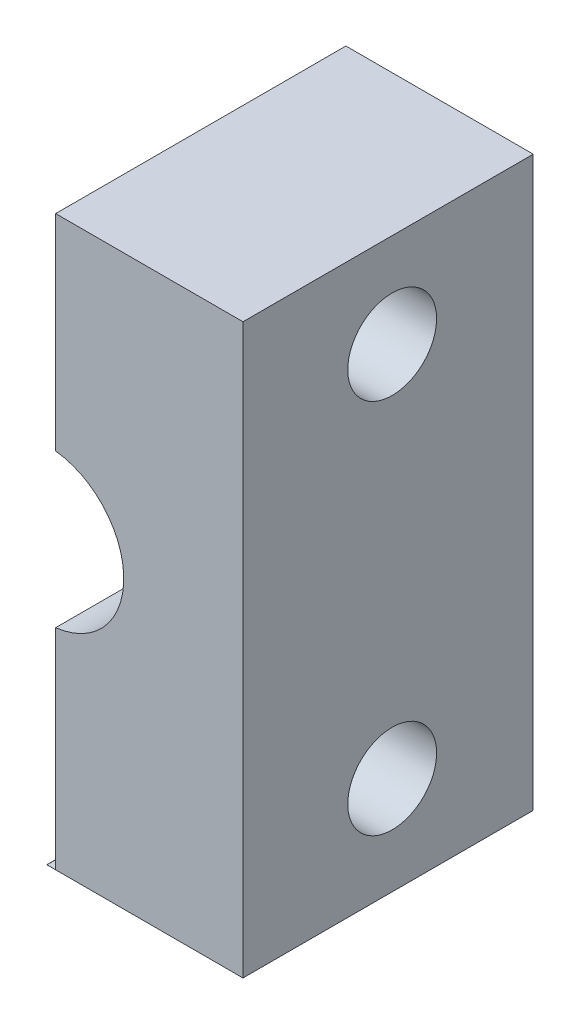
from build123d import *

# Parameters (mm, degrees)
EXTRUDE1_DEPTH = 9.8
SKETCH7_R      = 1.5
EXTRUDE3_DEPTH = 6.625
EXTRUDE4_DEPTH = 10.8


with BuildPart() as part:
    # Sketch5 → Extrude1 (new body)
    with BuildSketch(Plane.XY):
        with BuildLine():
            Line((-46.55, -2.6), (-46.55, -9.663597854))
            Line((-46.55, -9.663597854), (-39.925, -9.663597854))
            Line((-39.925, -9.663597854), (-39.925, 9.525))
            Line((-39.925, 9.525), (-46.55, 9.525))
            Line((-46.55, 9.525), (-46.55, 2.6))
            ThreePointArc((-46.55, 2.6), (-43.95, 0), (-46.55, -2.6))
        make_face()
    extrude(amount=EXTRUDE1_DEPTH)

    # Sketch7 → Extrude3 (cut)
    with BuildSketch(Plane(origin=(-39.925, 0, 0), x_dir=(0, 0, -1), z_dir=(1, 0, 0))):
        with Locations((-4.7625, 6.35)):
            Circle(SKETCH7_R)
        with Locations((-4.7625, -6.35)):
            Circle(SKETCH7_R)
    extrude(amount=-EXTRUDE3_DEPTH, mode=Mode.SUBTRACT)

    # Sketch9 → Extrude4 (cut, through all)
    with BuildSketch(Plane.XY.offset(9.8)):
        Polygon((-46.55, 9.525), (-46.55, -9.663597854), (-46.539158701, -9.658024196), (-46.25, -9.663597854), (-46.25, 9.525), align=None)
    extrude(amount=-EXTRUDE4_DEPTH, mode=Mode.SUBTRACT)


solid = part.part
